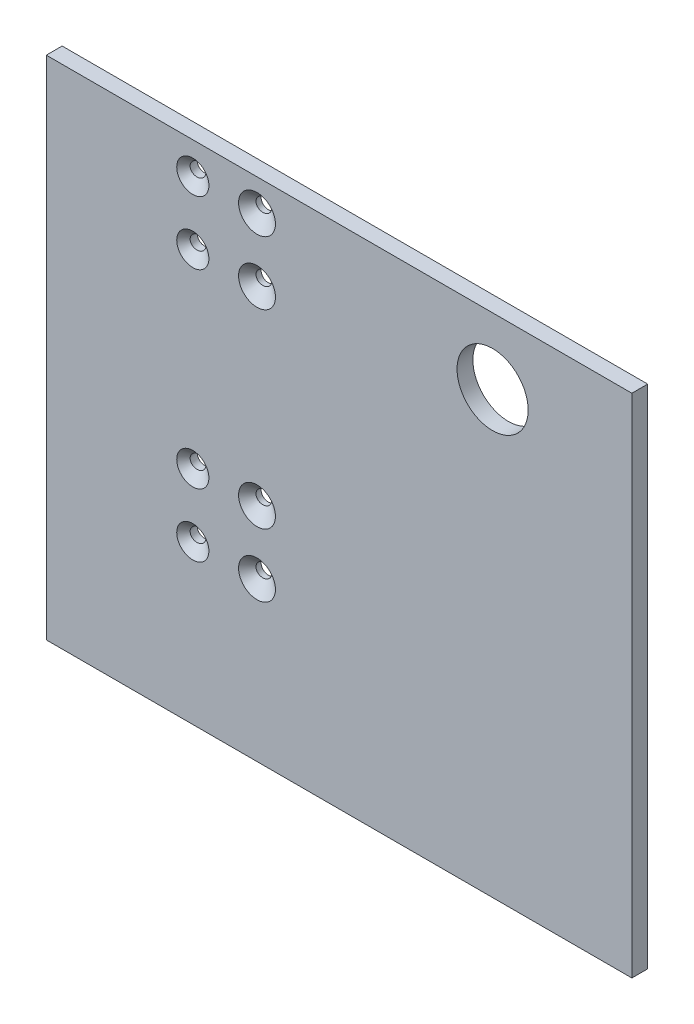
from build123d import *

# Parameters (mm, degrees)
SKETCH1_W                                          = 234.95
SKETCH1_H                                          = 203.2
BOSS_EXTRUDE1_DEPTH                                = 6.35
SKETCH2_R                                          = 14.2748
CUT_EXTRUDE1_DEPTH                                 = 7.35
CSK_FOR_10_FLAT_HEAD_MACHINE_SCREW_100_D           = 5.6134
CSK_FOR_10_FLAT_HEAD_MACHINE_SCREW_100_CSINK_D     = 17.78
CSK_FOR_10_FLAT_HEAD_MACHINE_SCREW_100_CSINK_ANGLE = 90
CSK_FOR_10_FLAT_HEAD_MACHINE_SCREW_2_D             = 5.6134
CSK_FOR_10_FLAT_HEAD_MACHINE_SCREW_2_CSINK_D       = 17.78
CSK_FOR_10_FLAT_HEAD_MACHINE_SCREW_2_CSINK_ANGLE   = 90


with BuildPart() as part:
    # Sketch1 → Boss-Extrude1 (new body)
    with BuildSketch(Plane.XY):
        Rectangle(SKETCH1_W, SKETCH1_H)
    extrude(amount=BOSS_EXTRUDE1_DEPTH)

    # Sketch2 → Cut-Extrude1 (cut, through all)
    with BuildSketch(Plane.XY.offset(6.35)):
        with Locations((61.595, 74.93)):
            Circle(SKETCH2_R)
    extrude(amount=-CUT_EXTRUDE1_DEPTH, mode=Mode.SUBTRACT)

    # CSK for _10 Flat Head Machine Screw _100 (through all)
    with Locations(Plane(origin=(271.17770657, -265.595089466, -36.034392524), x_dir=(-0.990861087, 0, 0.134886274), z_dir=(0.134886274, 0, 0.990861087))):
        with Locations((333.441972913, -227.495089466), (333.441972913, -252.895089466), (333.441972913, -329.095089466), (333.441972913, -354.495089466)):
            CounterSinkHole(CSK_FOR_10_FLAT_HEAD_MACHINE_SCREW_100_D / 2, CSK_FOR_10_FLAT_HEAD_MACHINE_SCREW_100_CSINK_D / 2, counter_sink_angle=CSK_FOR_10_FLAT_HEAD_MACHINE_SCREW_100_CSINK_ANGLE)

    # CSK for _10 Flat Head Machine Screw  2 (through all)
    with Locations(Plane(origin=(271.520317707, -265.595089466, -33.517605364), x_dir=(-0.990861087, 0, 0.134886274), z_dir=(0.134886274, 0, 0.990861087))):
        with Locations((308.041972913, -252.895089466), (308.041972913, -227.495089466), (308.041972913, -329.095089466), (308.041972913, -354.495089466)):
            CounterSinkHole(CSK_FOR_10_FLAT_HEAD_MACHINE_SCREW_2_D / 2, CSK_FOR_10_FLAT_HEAD_MACHINE_SCREW_2_CSINK_D / 2, counter_sink_angle=CSK_FOR_10_FLAT_HEAD_MACHINE_SCREW_2_CSINK_ANGLE)


solid = part.part
